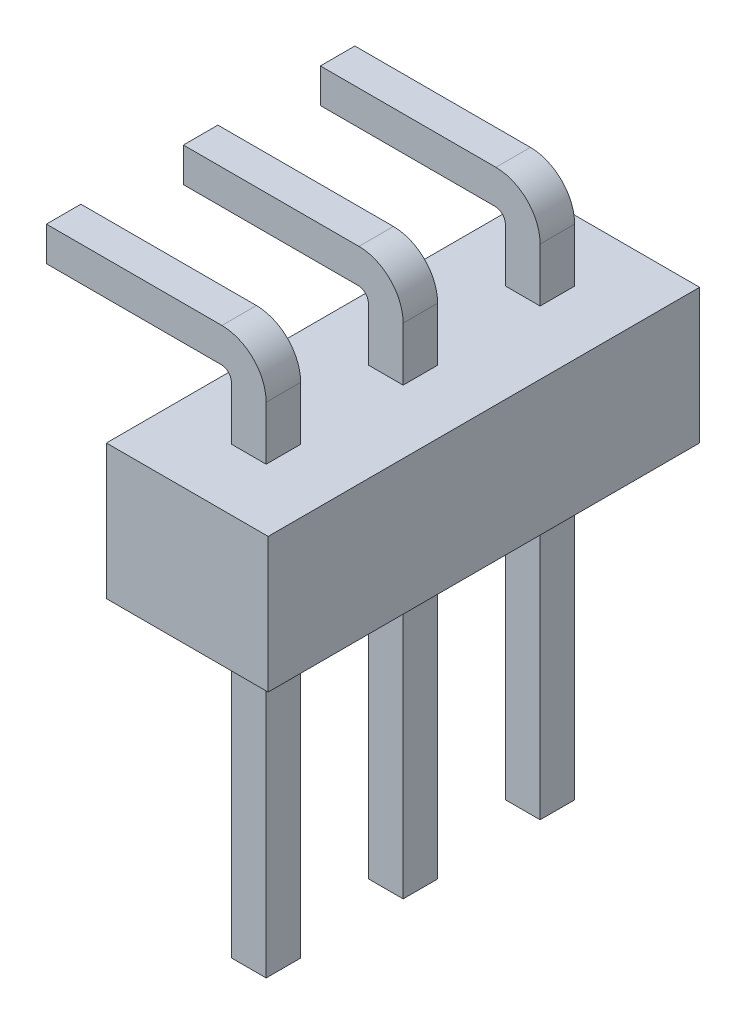
from build123d import *

# Parameters (mm, degrees)
SKETCH1_W       = 3
SKETCH1_H       = 2.5
EXTRUDE1_DEPTH  = 4
SKETCH2_W       = 0.645
SKETCH2_H       = 6
EXTRUDE2_DEPTH  = 0.64
LPATTERN1_COUNT = 3
LPATTERN1_PITCH = 2.54
CHAMFER1_SIZE   = 0.25


with BuildPart() as part:
    # Sketch1 → Extrude1 (new body, symmetric)
    with BuildSketch(Plane.XY):
        Rectangle(SKETCH1_W, SKETCH1_H)
    extrude(amount=EXTRUDE1_DEPTH, both=True)

    # Sketch2 → Extrude2 (add)
    with BuildSketch(Plane.XY.offset(2.86)):
        with BuildLine():
            Line((-0.3225, 1.25), (-0.3225, 2.245))
            ThreePointArc((-0.3225, 2.245), (-0.374776878, 2.375), (-0.5025, 2.43261663))
            Line((-0.5025, 2.43261663), (-4.0025, 2.43261663))
            Line((-4.0025, 2.43261663), (-4.0025, 3.06831282))
            Line((-4.0025, 3.06831282), (-0.4975, 3.06831282))
            ThreePointArc((-0.4975, 3.06831282), (0.082527742, 2.826), (0.3225, 2.245))
            Line((0.3225, 2.245), (0.3225, 1.25))
            Line((0.3225, 1.25), (-0.3225, 1.25))
        make_face()
        with Locations((0, -4.25)):
            Rectangle(SKETCH2_W, SKETCH2_H)
    extrude2 = extrude(amount=-EXTRUDE2_DEPTH)

    # LPattern1: Extrude2 ×3
    with Locations(*[(0, 0, -i * LPATTERN1_PITCH) for i in range(1, LPATTERN1_COUNT)]):
        add(extrude2)

    # Chamfer1
    chamfer1_edges = [part.edges().sort_by_distance(p)[0] for p in [
        (-4.0025, 2.750464725, 2.22),
        (-4.0025, 2.43261663, 2.54),
        (-4.0025, 3.06831282, 2.54),
        (-4.0025, 2.750464725, 2.86),
        (0, -7.25, 2.22),
        (0.3225, -7.25, 2.54),
        (-0.3225, -7.25, 2.54),
        (0, -7.25, 2.86),
        (-4.0025, 2.750464725, -0.32),
        (-4.0025, 2.43261663, 0),
        (-4.0025, 3.06831282, 0),
        (-4.0025, 2.750464725, 0.32),
        (0, -7.25, -0.32),
        (0.3225, -7.25, 0),
        (-0.3225, -7.25, 0),
        (0, -7.25, 0.32),
        (-4.0025, 2.750464725, -2.86),
        (-4.0025, 2.43261663, -2.54),
        (-4.0025, 3.06831282, -2.54),
        (-4.0025, 2.750464725, -2.22),
        (0, -7.25, -2.86),
        (0.3225, -7.25, -2.54),
        (-0.3225, -7.25, -2.54),
        (0, -7.25, -2.22),
    ]]
    chamfer(chamfer1_edges, length=CHAMFER1_SIZE)


solid = part.part
